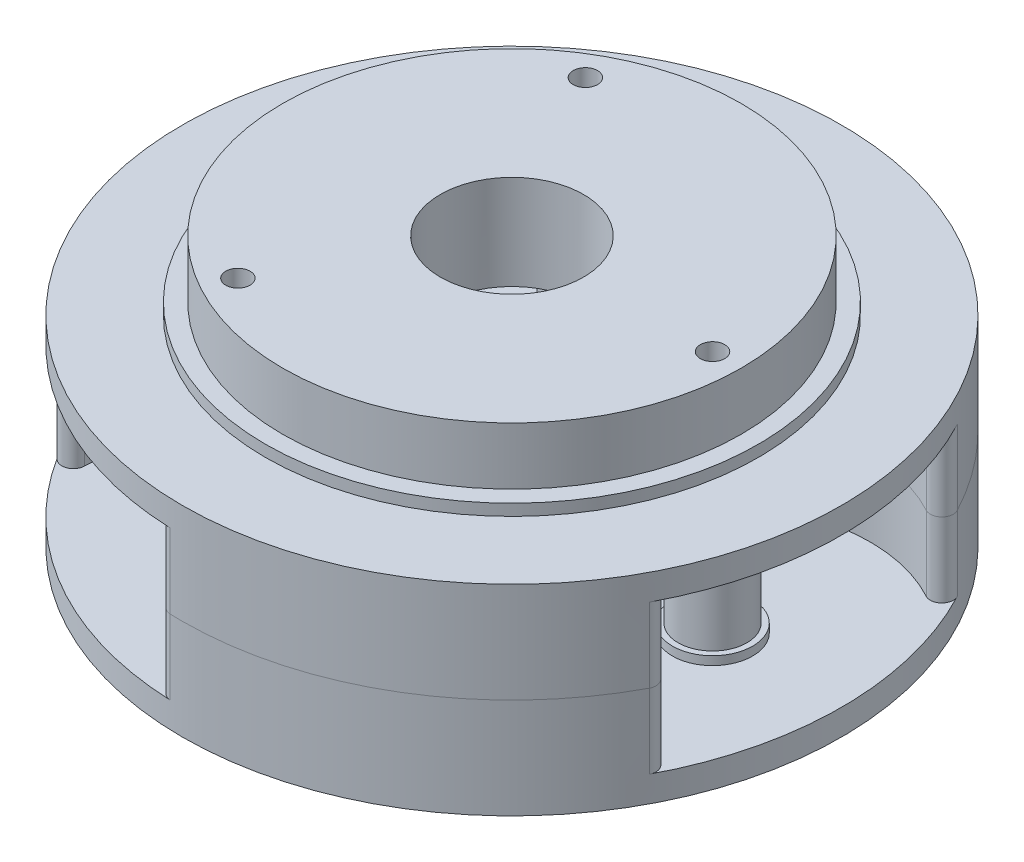
from build123d import *

# Parameters (mm, degrees)
SKETCH2_R                                  = 27.5
SKETCH2_R_2                                = 7
PLANET_CUTOUT_DEPTH                        = 13
PLANET_CUTOUT_FILLET_R                     = 2
SKETCH3_R                                  = 16
SKETCH3_R_2                                = 6
PLANET_BEARING_CUTOUT_DEPTH                = 11.5
PLANET_START                               = -24.5
SKETCH5_R                                  = 2.125
PLANET_PIN_HOLE_DEPTH                      = 55.0000001
PLANET_CUTOUT_PATTERN_COUNT                = 3
PLANET_CUTOUT_FILLET_OF_PLANET_CUTOUT_PA_R = 2
INDEXING_CUTOUT_DEPTH                      = 1.5
INDEXING_CUTOUT_PATTERN_COUNT              = 3
INDEXING_BOSSES_DEPTH                      = 1.5


with BuildPart() as part:
    # Sketch1 → Revolve1 (revolve)
    with BuildSketch(Plane(origin=(0, 0, 0), x_dir=(0, 0, -1), z_dir=(1, 0, 0))):
        Polygon((12.5, 29.5), (12.5, -29.5), (40, -29.5), (40, -19.5), (43, -19.5), (43, -17.5), (57.5, -17.5), (57.5, 17.5), (43, 17.5), (43, 19.5), (40, 19.5), (40, 29.5), align=None)
    revolve(axis=Axis((0, 40.826873385, 0), (0, -1, 0)))

    # Sketch2 → Planet Cutout (cut, symmetric)
    with BuildSketch(Plane(origin=(0, 0, 0), x_dir=(1, 0, 0), z_dir=(0, 1, 0))):
        with Locations((35, 0)):
            Circle(SKETCH2_R)
        with Locations((35, 0)):
            Circle(SKETCH2_R_2, mode=Mode.SUBTRACT)
    planet_cutout = extrude(amount=PLANET_CUTOUT_DEPTH, both=True, mode=Mode.SUBTRACT)

    # Planet Cutout Fillet
    planet_cutout_fillet_edges = [part.edges().sort_by_distance(p)[0] for p in [
        (53.928571429, 0, 19.948914348),
        (53.928571429, 0, -19.948914348),
        (8.928571429, 0, -8.748177653),
        (8.928571429, 0, 8.748177653),
    ]]
    fillet(planet_cutout_fillet_edges, radius=PLANET_CUTOUT_FILLET_R)

    # Sketch3 → Planet Bearing Cutout (cut, symmetric)
    with BuildSketch(Plane(origin=(0, 0, 0), x_dir=(1, 0, 0), z_dir=(0, 1, 0))):
        with Locations((35, 0)):
            Circle(SKETCH3_R)
        with Locations((35, 0)):
            Circle(SKETCH3_R_2, mode=Mode.SUBTRACT)
    planet_bearing_cutout = extrude(amount=PLANET_BEARING_CUTOUT_DEPTH, both=True, mode=Mode.SUBTRACT)

    # Sketch5 → Planet Pin Hole (cut)
    with BuildSketch(Plane(origin=(0, 0, 0), x_dir=(1, 0, 0), z_dir=(0, 1, 0)).offset(PLANET_START)):
        with Locations((35, 0)):
            Circle(SKETCH5_R)
    planet_pin_hole = extrude(amount=PLANET_PIN_HOLE_DEPTH, mode=Mode.SUBTRACT)

    # Planet Cutout Pattern: Planet Cutout, Planet Bearing Cutout, Planet Pin Hole ×3 about axis
    planet_cutout_pattern_axis = Axis((0, 0, 0), (0, 1, 0))
    for i in range(1, PLANET_CUTOUT_PATTERN_COUNT):
        add(planet_cutout.rotate(planet_cutout_pattern_axis, i * 360 / PLANET_CUTOUT_PATTERN_COUNT), mode=Mode.SUBTRACT)
        add(planet_bearing_cutout.rotate(planet_cutout_pattern_axis, i * 360 / PLANET_CUTOUT_PATTERN_COUNT), mode=Mode.SUBTRACT)
        add(planet_pin_hole.rotate(planet_cutout_pattern_axis, i * 360 / PLANET_CUTOUT_PATTERN_COUNT), mode=Mode.SUBTRACT)

    # Planet Cutout Fillet of Planet Cutout Pa
    planet_cutout_fillet_of_planet_cutout_pa_edges = [part.edges().sort_by_distance(p)[0] for p in [
        (-9.688019111, 0, -56.677970021),
        (-44.240552318, 0, -36.729055673),
        (-12.040429798, 0, -3.35828085),
        (3.11185837, 0, -12.106458503),
        (-44.240552318, 0, 36.729055673),
        (-9.688019111, 0, 56.677970021),
        (3.11185837, 0, 12.106458503),
        (-12.040429798, 0, 3.35828085),
    ]]
    fillet(planet_cutout_fillet_of_planet_cutout_pa_edges, radius=PLANET_CUTOUT_FILLET_OF_PLANET_CUTOUT_PA_R)


with BuildPart() as body_2:
    # Split1: the piece on the far side of the plane
    add(part.part)
    split(bisect_by=Plane.ZX, keep=Keep.BOTTOM)

    # Sketch6 → Indexing Cutout (cut)
    with BuildSketch(Plane(origin=(0, 0, 0), x_dir=(1, 0, 0), z_dir=(0, 1, 0))):
        with BuildLine():
            ThreePointArc((41.649791956, 35.150317638), (27.25, 47.198384506), (9.616172048, 53.644936715))
            ThreePointArc((9.616172048, 53.644936715), (6.524681483, 52.252560784), (6.705930299, 48.866829915))
            ThreePointArc((6.705930299, 48.866829915), (11.768334801, 38.890782954), (12.893178356, 27.760455947))
            ThreePointArc((12.893178356, 27.760455947), (14.382671309, 24.911517455), (17.594670893, 25.046047965))
            ThreePointArc((17.594670893, 25.046047965), (27.796238611, 29.637068375), (38.966950959, 30.240920953))
            ThreePointArc((38.966950959, 30.240920953), (41.98970431, 31.776820308), (41.649791956, 35.150317638))
        make_face()
    indexing_cutout = extrude(amount=-INDEXING_CUTOUT_DEPTH, mode=Mode.SUBTRACT)

    # Indexing Cutout Pattern: Indexing Cutout ×3 about axis
    indexing_cutout_pattern_axis = Axis((0, 0, 0), (0, 1, 0))
    for i in range(1, INDEXING_CUTOUT_PATTERN_COUNT):
        add(indexing_cutout.rotate(indexing_cutout_pattern_axis, i * 360 / INDEXING_CUTOUT_PATTERN_COUNT), mode=Mode.SUBTRACT)


with BuildPart() as part_1:
    add(part.part)

    # Split1
    split(bisect_by=Plane.ZX, keep=Keep.TOP)

    # Sketch9 → Indexing Bosses (add)
    with BuildSketch(Plane.XZ):
        with BuildLine():
            ThreePointArc((41.458737864, -34.989077649), (41.770324189, -31.896705096), (38.999466951, -30.488797354))
            ThreePointArc((38.999466951, -30.488797354), (27.737191387, -29.879995165), (17.452004261, -25.25134344))
            ThreePointArc((17.452004261, -25.25134344), (14.507671309, -25.128023806), (13.142302769, -27.739550757))
            ThreePointArc((13.142302769, -27.739550757), (12.008239184, -38.961109953), (6.904339564, -49.018927791))
            ThreePointArc((6.904339564, -49.018927791), (6.738194816, -52.12251442), (9.572061167, -53.398859024))
            ThreePointArc((9.572061167, -53.398859024), (27.125, -46.981878155), (41.458737864, -34.989077649))
        make_face()
        with BuildLine():
            ThreePointArc((-51.030799031, -18.409781375), (-48.508519005, -20.225809324), (-45.903806515, -18.530130436))
            ThreePointArc((-45.903806515, -18.530130436), (-39.745430571, -9.081114788), (-30.59430703, -2.488207317))
            ThreePointArc((-30.59430703, -2.488207317), (-29.015342618, 0), (-30.59430703, 2.488207317))
            ThreePointArc((-30.59430703, 2.488207317), (-39.745430571, 9.081114788), (-45.903806515, 18.530130436))
            ThreePointArc((-45.903806515, 18.530130436), (-48.508519005, 20.225809324), (-51.030799031, 18.409781375))
            ThreePointArc((-51.030799031, 18.409781375), (-54.25, 0), (-51.030799031, -18.409781375))
        make_face()
        with BuildLine():
            ThreePointArc((9.572061167, 53.398859024), (6.738194816, 52.12251442), (6.904339564, 49.018927791))
            ThreePointArc((6.904339564, 49.018927791), (12.008239184, 38.961109953), (13.142302769, 27.739550757))
            ThreePointArc((13.142302769, 27.739550757), (14.507671309, 25.128023806), (17.452004261, 25.25134344))
            ThreePointArc((17.452004261, 25.25134344), (27.737191387, 29.879995165), (38.999466951, 30.488797354))
            ThreePointArc((38.999466951, 30.488797354), (41.770324189, 31.896705096), (41.458737864, 34.989077649))
            ThreePointArc((41.458737864, 34.989077649), (27.125, 46.981878155), (9.572061167, 53.398859024))
        make_face()
    extrude(amount=INDEXING_BOSSES_DEPTH)


solid = Compound([body_2.part, part_1.part])
